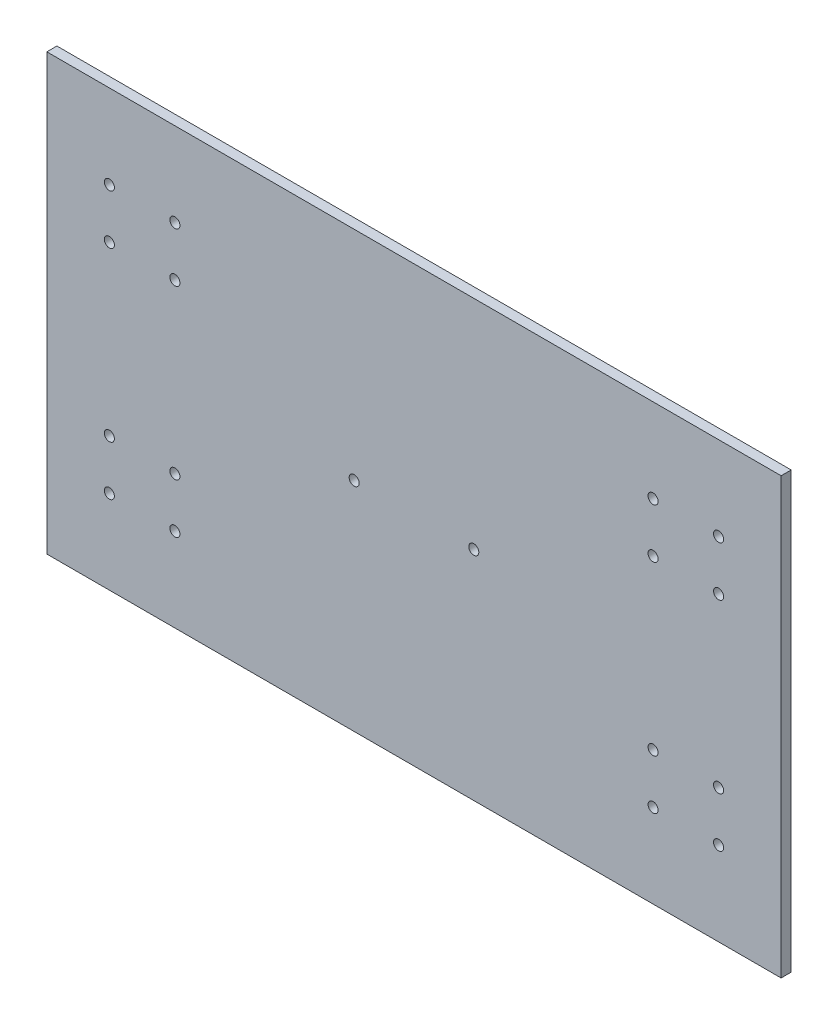
from build123d import *

# Parameters (mm, degrees)
SKETCH1_W           = 270.1
SKETCH1_H           = 160
SKETCH1_R           = 1.85
BOSS_EXTRUDE1_DEPTH = 3.7


with BuildPart() as part:
    # Sketch1 → Boss-Extrude1 (new body)
    with BuildSketch(Plane.XY):
        with Locations((135.05, 80)):
            Rectangle(SKETCH1_W, SKETCH1_H)
        with Locations((23, 49.15)):
            Circle(SKETCH1_R, mode=Mode.SUBTRACT)
        with Locations((47.1, 49.15)):
            Circle(SKETCH1_R, mode=Mode.SUBTRACT)
        with Locations((23, 30.85)):
            Circle(SKETCH1_R, mode=Mode.SUBTRACT)
        with Locations((47.1, 30.85)):
            Circle(SKETCH1_R, mode=Mode.SUBTRACT)
        with Locations((223, 30.85)):
            Circle(SKETCH1_R, mode=Mode.SUBTRACT)
        with Locations((223, 49.15)):
            Circle(SKETCH1_R, mode=Mode.SUBTRACT)
        with Locations((247.1, 49.15)):
            Circle(SKETCH1_R, mode=Mode.SUBTRACT)
        with Locations((247.1, 30.85)):
            Circle(SKETCH1_R, mode=Mode.SUBTRACT)
        with Locations((23, 129.15)):
            Circle(SKETCH1_R, mode=Mode.SUBTRACT)
        with Locations((23, 110.85)):
            Circle(SKETCH1_R, mode=Mode.SUBTRACT)
        with Locations((47.1, 110.85)):
            Circle(SKETCH1_R, mode=Mode.SUBTRACT)
        with Locations((47.1, 129.15)):
            Circle(SKETCH1_R, mode=Mode.SUBTRACT)
        with Locations((223, 110.85)):
            Circle(SKETCH1_R, mode=Mode.SUBTRACT)
        with Locations((223, 129.15)):
            Circle(SKETCH1_R, mode=Mode.SUBTRACT)
        with Locations((247.1, 129.15)):
            Circle(SKETCH1_R, mode=Mode.SUBTRACT)
        with Locations((247.1, 110.85)):
            Circle(SKETCH1_R, mode=Mode.SUBTRACT)
        with Locations((113.05, 80)):
            Circle(SKETCH1_R, mode=Mode.SUBTRACT)
        with Locations((157.05, 80)):
            Circle(SKETCH1_R, mode=Mode.SUBTRACT)
    extrude(amount=BOSS_EXTRUDE1_DEPTH)


solid = part.part
